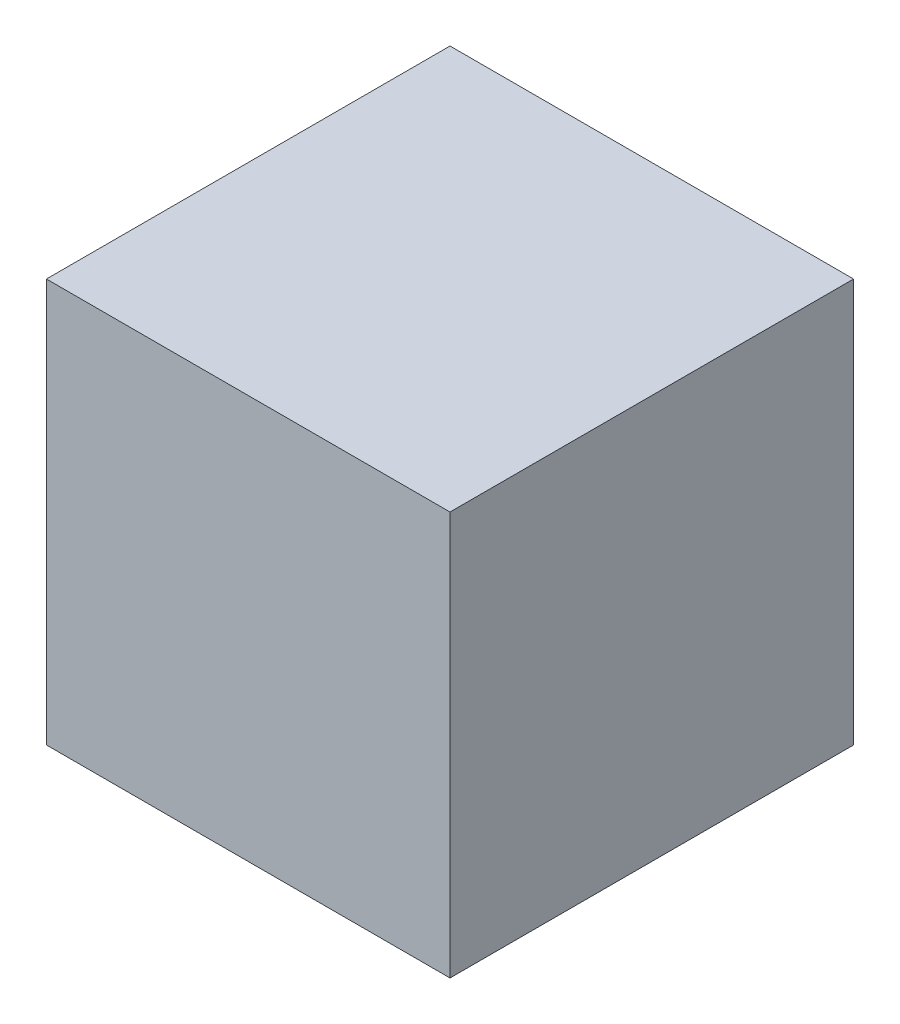
from build123d import *

# Parameters (mm, degrees)
SKETCH1_W           = 150
SKETCH1_H           = 150
BOSS_EXTRUDE1_DEPTH = 150


with BuildPart() as part:
    # Sketch1 → Boss-Extrude1 (new body)
    with BuildSketch(Plane(origin=(0, 0, 0), x_dir=(1, 0, 0), z_dir=(0, 1, 0))):
        Rectangle(SKETCH1_W, SKETCH1_H)
    extrude(amount=BOSS_EXTRUDE1_DEPTH)


solid = part.part
